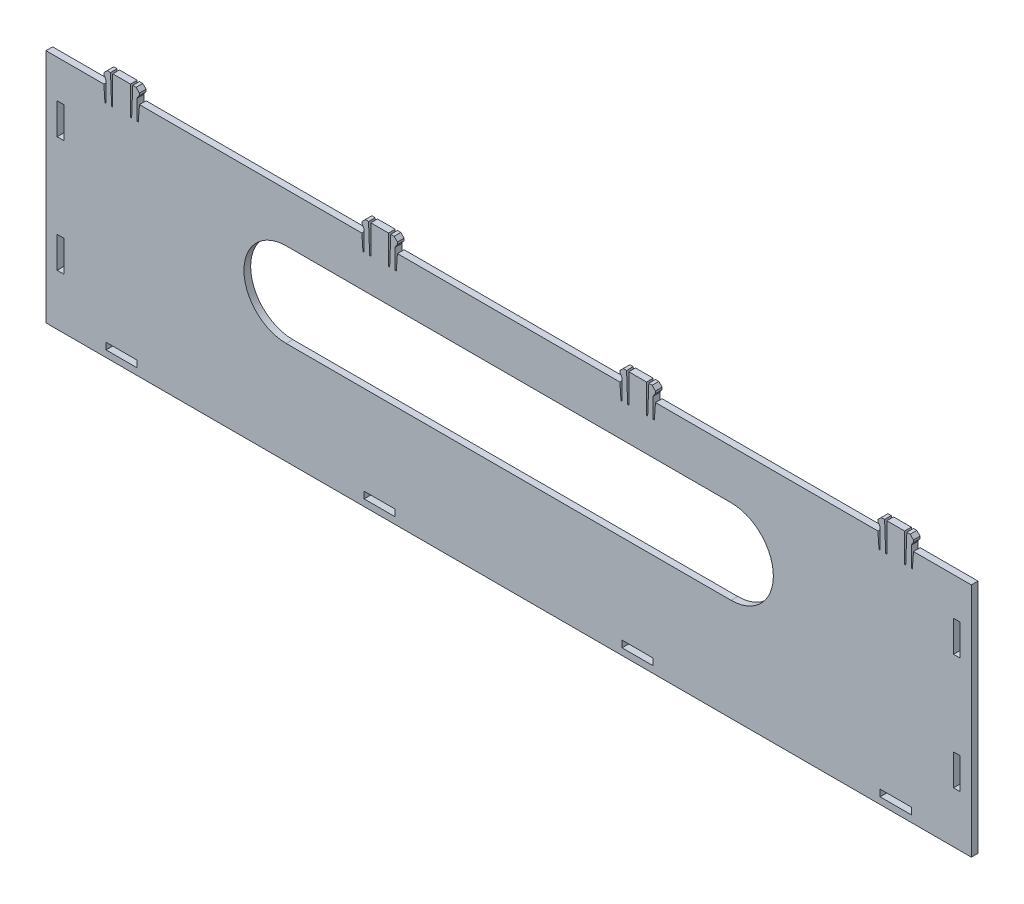
from build123d import *

# Parameters (mm, degrees)
BOSS_EXTRUDE1_DEPTH = 3
CUT_EXTRUDE2_DEPTH  = 4
SKETCH8_W           = 14
SKETCH8_H           = 3
CUT_EXTRUDE3_DEPTH  = 3
SKETCH9_W           = 3
SKETCH9_H           = 14
CUT_EXTRUDE4_DEPTH  = 3


with BuildPart() as part:
    # Sketch1 → Boss-Extrude1 (new body)
    with BuildSketch(Plane.XY):
        Polygon((208, 50), (182, 50), (181.5, 42.997828908), (181, 42.997828908), (181, 51.997828908), (181.5, 52.997828908), (182, 53.497828908), (182, 54.497828908), (180.5, 55.997828908), (179, 55.997828908), (178.5, 42.997828908), (178, 42.997828908), (178, 55.997828908), (170, 55.997828908), (170, 42.997828908), (169.5, 42.997828908), (169, 55.997828908), (167.5, 55.997828908), (166, 54.497828908), (166, 53.497828908), (166.5, 52.997828908), (167, 51.997828908), (167, 42.997828908), (166.5, 42.997828908), (166, 50), (66, 50), (65.5, 42.997828908), (65, 42.997828908), (65, 51.997828908), (65.5, 52.997828908), (66, 53.497828908), (66, 54.497828908), (64.5, 55.997828908), (63, 55.997828908), (62.5, 42.997828908), (62, 42.997828908), (62, 55.997828908), (54, 55.997828908), (54, 42.997828908), (53.5, 42.997828908), (53, 55.997828908), (51.5, 55.997828908), (50, 54.497828908), (50, 53.497828908), (50.5, 52.997828908), (51, 51.997828908), (51, 42.997828908), (50.5, 42.997828908), (50, 50), (-50, 50), (-50.5, 42.997828908), (-51, 42.997828908), (-51, 51.997828908), (-50.5, 52.997828908), (-50, 53.497828908), (-50, 54.497828908), (-51.5, 55.997828908), (-53, 55.997828908), (-53.5, 42.997828908), (-54, 42.997828908), (-54, 55.997828908), (-62, 55.997828908), (-62, 42.997828908), (-62.5, 42.997828908), (-63, 55.997828908), (-64.5, 55.997828908), (-66, 54.497828908), (-66, 53.497828908), (-65.5, 52.997828908), (-65, 51.997828908), (-65, 42.997828908), (-65.5, 42.997828908), (-66, 50), (-166, 50), (-166.5, 42.997828908), (-167, 42.997828908), (-167, 51.997828908), (-166.5, 52.997828908), (-166, 53.497828908), (-166, 54.497828908), (-167.5, 55.997828908), (-169, 55.997828908), (-169.5, 42.997828908), (-170, 42.997828908), (-170, 55.997828908), (-178, 55.997828908), (-178, 42.997828908), (-178.5, 42.997828908), (-179, 55.997828908), (-180.5, 55.997828908), (-182, 54.497828908), (-182, 53.497828908), (-181.5, 52.997828908), (-181, 51.997828908), (-181, 42.997828908), (-181.5, 42.997828908), (-182, 50), (-208, 50), (-208, -56), (208, -56), align=None)
    extrude(amount=BOSS_EXTRUDE1_DEPTH)

    # Sketch4 → Cut-Extrude2 (cut, through all)
    with BuildSketch(Plane.XY.offset(3)):
        with BuildLine():
            Line((-100, 28), (100, 28))
            ThreePointArc((100, 28), (119, 9), (100, -10))
            Line((100, -10), (-100, -10))
            ThreePointArc((-100, -10), (-119, 9), (-100, 28))
        make_face()
    extrude(amount=-CUT_EXTRUDE2_DEPTH, mode=Mode.SUBTRACT)

    # Sketch8 → Cut-Extrude3 (cut)
    with BuildSketch(Plane.XY.offset(3)):
        with Locations((174, -51.5)):
            Rectangle(SKETCH8_W, SKETCH8_H)
        with Locations((-174, -51.5)):
            Rectangle(SKETCH8_W, SKETCH8_H)
        with Locations((58, -51.5)):
            Rectangle(SKETCH8_W, SKETCH8_H)
        with Locations((-58, -51.5)):
            Rectangle(SKETCH8_W, SKETCH8_H)
    extrude(amount=-CUT_EXTRUDE3_DEPTH, mode=Mode.SUBTRACT)

    # Sketch9 → Cut-Extrude4 (cut)
    with BuildSketch(Plane.XY.offset(3)):
        with Locations((201.5, 26)):
            Rectangle(SKETCH9_W, SKETCH9_H)
        with Locations((-201.5, 26)):
            Rectangle(SKETCH9_W, SKETCH9_H)
        with Locations((-201.5, -26)):
            Rectangle(SKETCH9_W, SKETCH9_H)
        with Locations((201.5, -26)):
            Rectangle(SKETCH9_W, SKETCH9_H)
    extrude(amount=-CUT_EXTRUDE4_DEPTH, mode=Mode.SUBTRACT)


solid = part.part
